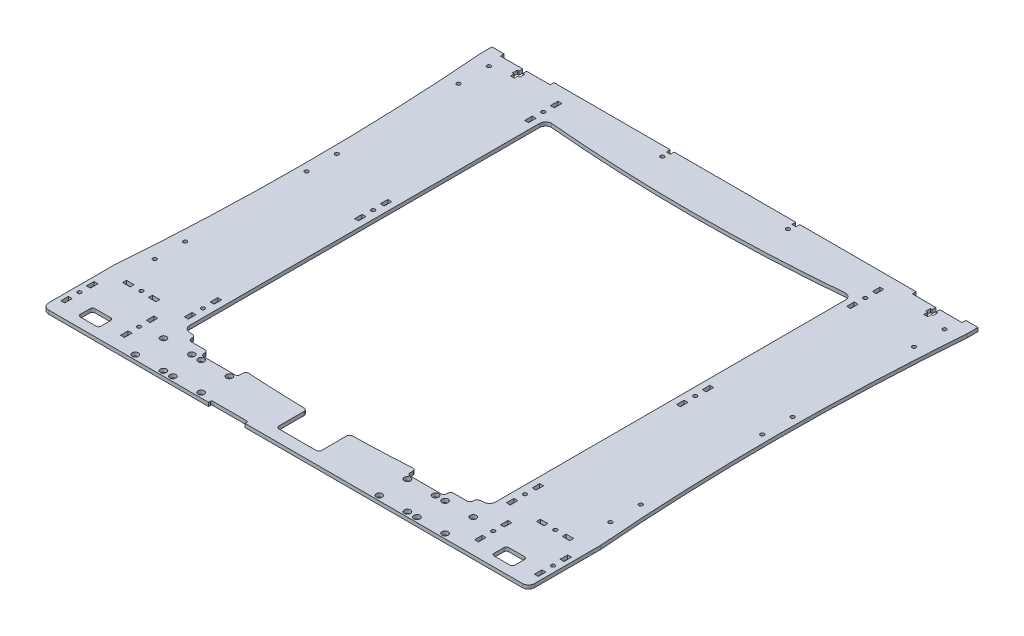
from build123d import *

# Parameters (mm, degrees)
CROQUIS1_W              = 3.2
CROQUIS1_H              = 6.2
CROQUIS1_R              = 1.55
CROQUIS1_R_2            = 2.55
CROQUIS1_W_2            = 6.2
CROQUIS1_H_2            = 3.2
SALIENTE_EXTRUIR1_DEPTH = 3
CORTAR_EXTRUIR1_DEPTH   = 3
REDONDEO1_R             = 5
CORTAR_EXTRUIR3_DEPTH   = 3
CROQUIS5_W              = 30
CROQUIS5_H              = 11
CROQUIS5_W_2            = 35
CROQUIS5_H_2            = 25.246672812
CORTAR_EXTRUIR4_DEPTH   = 3
REDONDEO2_R             = 2
CORTAR_EXTRUIR5_DEPTH   = 3
CROQUIS7_W              = 16
CROQUIS7_H              = 5.5
CORTAR_EXTRUIR6_DEPTH   = 3
REDONDEO3_R             = 2.5


with BuildPart() as part:
    # Croquis1 → Saliente-Extruir1 (new body)
    with BuildSketch(Plane(origin=(0, 0, 0), x_dir=(1, 0, 0), z_dir=(0, 1, 0))):
        Polygon((0, 370), (0, 0), (400, 0), (400, 370), (390, 370), (390, 366.9), (371.6, 366.9), (371.6, 363.9), (373, 363.9), (373, 359.9), (371.6, 359.9), (371.6, 356.9), (368.4, 356.9), (368.4, 359.9), (367, 359.9), (367, 363.9), (368.4, 363.9), (368.4, 366.9), (349, 366.9), (349, 370), (253.3, 370), (253.3, 366.9), (250, 366.9), (250, 370), (150, 370), (150, 366.9), (146.7, 366.9), (146.7, 370), (51, 370), (51, 366.9), (31.6, 366.9), (31.6, 363.9), (33, 363.9), (33, 359.9), (31.6, 359.9), (31.6, 356.9), (28.4, 356.9), (28.4, 359.9), (27, 359.9), (27, 363.9), (28.4, 363.9), (28.4, 366.9), (10, 366.9), (10, 370), align=None)
        with Locations((5.1, 14.7)):
            Rectangle(CROQUIS1_W, CROQUIS1_H, mode=Mode.SUBTRACT)
        with Locations((5.1, 25.3)):
            Circle(CROQUIS1_R, mode=Mode.SUBTRACT)
        with Locations((5.1, 35.9)):
            Rectangle(CROQUIS1_W, CROQUIS1_H, mode=Mode.SUBTRACT)
        with Locations((72.5, 3.9)):
            Circle(CROQUIS1_R_2, mode=Mode.SUBTRACT)
        with Locations((54.3, 14.7)):
            Rectangle(CROQUIS1_W, CROQUIS1_H, mode=Mode.SUBTRACT)
        with Locations((95.7, 3.9)):
            Circle(CROQUIS1_R_2, mode=Mode.SUBTRACT)
        with Locations((54.3, 25.3)):
            Circle(CROQUIS1_R, mode=Mode.SUBTRACT)
        with Locations((72.5, 27.1)):
            Circle(CROQUIS1_R_2, mode=Mode.SUBTRACT)
        with Locations((54.3, 35.9)):
            Rectangle(CROQUIS1_W, CROQUIS1_H, mode=Mode.SUBTRACT)
        with Locations((95.7, 27.1)):
            Circle(CROQUIS1_R_2, mode=Mode.SUBTRACT)
        with Locations((19.1, 51.6)):
            Rectangle(CROQUIS1_W_2, CROQUIS1_H_2, mode=Mode.SUBTRACT)
        with Locations((29.7, 51.8)):
            Circle(CROQUIS1_R, mode=Mode.SUBTRACT)
        with Locations((40.3, 51.6)):
            Rectangle(CROQUIS1_W_2, CROQUIS1_H_2, mode=Mode.SUBTRACT)
        with Locations((12.5, 79.9)):
            Circle(CROQUIS1_R, mode=Mode.SUBTRACT)
        with Locations((67.5, 54.1)):
            Rectangle(CROQUIS1_W, CROQUIS1_H, mode=Mode.SUBTRACT)
        with Locations((67.5, 64.7)):
            Circle(CROQUIS1_R, mode=Mode.SUBTRACT)
        with Locations((67.5, 75.3)):
            Rectangle(CROQUIS1_W, CROQUIS1_H, mode=Mode.SUBTRACT)
        with Locations((103.5, 3.9)):
            Circle(CROQUIS1_R_2, mode=Mode.SUBTRACT)
        with Locations((126.7, 3.9)):
            Circle(CROQUIS1_R_2, mode=Mode.SUBTRACT)
        with Locations((103.5, 27.1)):
            Circle(CROQUIS1_R_2, mode=Mode.SUBTRACT)
        with Locations((126.7, 27.1)):
            Circle(CROQUIS1_R_2, mode=Mode.SUBTRACT)
        with Locations((12.5, 104.9)):
            Circle(CROQUIS1_R, mode=Mode.SUBTRACT)
        with Locations((273.3, 3.9)):
            Circle(CROQUIS1_R_2, mode=Mode.SUBTRACT)
        with Locations((296.5, 3.9)):
            Circle(CROQUIS1_R_2, mode=Mode.SUBTRACT)
        with Locations((273.3, 27.1)):
            Circle(CROQUIS1_R_2, mode=Mode.SUBTRACT)
        with Locations((296.5, 27.1)):
            Circle(CROQUIS1_R_2, mode=Mode.SUBTRACT)
        with Locations((304.3, 3.9)):
            Circle(CROQUIS1_R_2, mode=Mode.SUBTRACT)
        with Locations((327.5, 3.9)):
            Circle(CROQUIS1_R_2, mode=Mode.SUBTRACT)
        with Locations((345.7, 14.7)):
            Rectangle(CROQUIS1_W, CROQUIS1_H, mode=Mode.SUBTRACT)
        with Locations((304.3, 27.1)):
            Circle(CROQUIS1_R_2, mode=Mode.SUBTRACT)
        with Locations((327.5, 27.1)):
            Circle(CROQUIS1_R_2, mode=Mode.SUBTRACT)
        with Locations((345.7, 25.3)):
            Circle(CROQUIS1_R, mode=Mode.SUBTRACT)
        with Locations((345.7, 35.9)):
            Rectangle(CROQUIS1_W, CROQUIS1_H, mode=Mode.SUBTRACT)
        with Locations((394.9, 14.7)):
            Rectangle(CROQUIS1_W, CROQUIS1_H, mode=Mode.SUBTRACT)
        with Locations((394.9, 25.3)):
            Circle(CROQUIS1_R, mode=Mode.SUBTRACT)
        with Locations((394.9, 35.9)):
            Rectangle(CROQUIS1_W, CROQUIS1_H, mode=Mode.SUBTRACT)
        with Locations((332.5, 54.1)):
            Rectangle(CROQUIS1_W, CROQUIS1_H, mode=Mode.SUBTRACT)
        with Locations((332.5, 64.7)):
            Circle(CROQUIS1_R, mode=Mode.SUBTRACT)
        with Locations((332.5, 75.3)):
            Rectangle(CROQUIS1_W, CROQUIS1_H, mode=Mode.SUBTRACT)
        with Locations((359.7, 51.6)):
            Rectangle(CROQUIS1_W_2, CROQUIS1_H_2, mode=Mode.SUBTRACT)
        with Locations((370.3, 51.8)):
            Circle(CROQUIS1_R, mode=Mode.SUBTRACT)
        with Locations((380.9, 51.6)):
            Rectangle(CROQUIS1_W_2, CROQUIS1_H_2, mode=Mode.SUBTRACT)
        with Locations((387.5, 79.9)):
            Circle(CROQUIS1_R, mode=Mode.SUBTRACT)
        with Locations((387.5, 104.9)):
            Circle(CROQUIS1_R, mode=Mode.SUBTRACT)
        with Locations((12.5, 204.9)):
            Circle(CROQUIS1_R, mode=Mode.SUBTRACT)
        with Locations((12.5, 229.9)):
            Circle(CROQUIS1_R, mode=Mode.SUBTRACT)
        with Locations((67.5, 194.1)):
            Rectangle(CROQUIS1_W, CROQUIS1_H, mode=Mode.SUBTRACT)
        with Locations((67.5, 204.7)):
            Circle(CROQUIS1_R, mode=Mode.SUBTRACT)
        with Locations((67.5, 215.3)):
            Rectangle(CROQUIS1_W, CROQUIS1_H, mode=Mode.SUBTRACT)
        with Locations((12.5, 329.9)):
            Circle(CROQUIS1_R, mode=Mode.SUBTRACT)
        with Locations((12.5, 354.9)):
            Circle(CROQUIS1_R, mode=Mode.SUBTRACT)
        with Locations((67.5, 334.1)):
            Rectangle(CROQUIS1_W, CROQUIS1_H, mode=Mode.SUBTRACT)
        with Locations((67.5, 344.7)):
            Circle(CROQUIS1_R, mode=Mode.SUBTRACT)
        with Locations((67.5, 355.3)):
            Rectangle(CROQUIS1_W, CROQUIS1_H, mode=Mode.SUBTRACT)
        with Locations((148.35, 361.9)):
            Circle(CROQUIS1_R, mode=Mode.SUBTRACT)
        with Locations((332.5, 194.1)):
            Rectangle(CROQUIS1_W, CROQUIS1_H, mode=Mode.SUBTRACT)
        with Locations((332.5, 204.7)):
            Circle(CROQUIS1_R, mode=Mode.SUBTRACT)
        with Locations((332.5, 215.3)):
            Rectangle(CROQUIS1_W, CROQUIS1_H, mode=Mode.SUBTRACT)
        with Locations((387.5, 204.9)):
            Circle(CROQUIS1_R, mode=Mode.SUBTRACT)
        with Locations((387.5, 229.9)):
            Circle(CROQUIS1_R, mode=Mode.SUBTRACT)
        with Locations((251.65, 361.9)):
            Circle(CROQUIS1_R, mode=Mode.SUBTRACT)
        with Locations((332.5, 334.1)):
            Rectangle(CROQUIS1_W, CROQUIS1_H, mode=Mode.SUBTRACT)
        with Locations((332.5, 344.7)):
            Circle(CROQUIS1_R, mode=Mode.SUBTRACT)
        with Locations((332.5, 355.3)):
            Rectangle(CROQUIS1_W, CROQUIS1_H, mode=Mode.SUBTRACT)
        with Locations((387.5, 329.9)):
            Circle(CROQUIS1_R, mode=Mode.SUBTRACT)
        with Locations((387.5, 354.9)):
            Circle(CROQUIS1_R, mode=Mode.SUBTRACT)
    extrude(amount=SALIENTE_EXTRUIR1_DEPTH)

    # Croquis2 → Cortar-Extruir1 (cut)
    with BuildSketch(Plane(origin=(0, 3, 0), x_dir=(1, 0, 0), z_dir=(0, 1, 0))):
        with BuildLine():
            Line((74.1, 335), (74.1, 47.1))
            ThreePointArc((74.1, 47.1), (75.564466094, 43.564466094), (79.1, 42.1))
            ThreePointArc((79.1, 42.1), (200, 35.100499668), (320.9, 42.1))
            ThreePointArc((320.9, 42.1), (324.435533906, 43.564466094), (325.9, 47.1))
            Line((325.9, 47.1), (325.9, 335))
            ThreePointArc((325.9, 335), (324.435533906, 338.535533906), (320.9, 340))
            ThreePointArc((320.9, 340), (200, 334.578561616), (79.1, 340))
            ThreePointArc((79.1, 340), (75.564466094, 338.535533906), (74.1, 335))
        make_face()
    extrude(amount=-CORTAR_EXTRUIR1_DEPTH, mode=Mode.SUBTRACT)

    # Redondeo1
    redondeo1_edges = [part.edges().sort_by_distance(p)[0] for p in [
        (400, 1.5, 0),
        (0, 1.5, 0),
    ]]
    fillet(redondeo1_edges, radius=REDONDEO1_R)

    # Croquis4 → Cortar-Extruir3 (cut)
    with BuildSketch(Plane(origin=(0, 3, 0), x_dir=(1, 0, 0), z_dir=(0, 1, 0))):
        with BuildLine():
            ThreePointArc((0, 361), (6, 210.1), (0, 59.2))
            Line((0, 59.2), (0, 361))
        make_face()
        with BuildLine():
            Line((400, 361), (400, 59.2))
            ThreePointArc((400, 59.2), (394, 210.1), (400, 361))
        make_face()
    extrude(amount=-CORTAR_EXTRUIR3_DEPTH, mode=Mode.SUBTRACT)

    # Croquis5 → Cortar-Extruir4 (cut)
    with BuildSketch(Plane(origin=(0, 3, 0), x_dir=(1, 0, 0), z_dir=(0, 1, 0))):
        with Locations((115.100000017, 36)):
            Rectangle(CROQUIS5_W, CROQUIS5_H)
        with Locations((284.899999983, 36)):
            Rectangle(CROQUIS5_W, CROQUIS5_H)
        with Locations((200, 22.623336406)):
            Rectangle(CROQUIS5_W_2, CROQUIS5_H_2)
        with BuildLine():
            Line((23.2, 20), (36.2, 20))
            ThreePointArc((36.2, 20), (37.614213562, 19.414213562), (38.2, 18))
            Line((38.2, 18), (38.2, 10))
            ThreePointArc((38.2, 10), (37.614213562, 8.585786438), (36.2, 8))
            Line((36.2, 8), (23.2, 8))
            ThreePointArc((23.2, 8), (21.785786438, 8.585786438), (21.2, 10))
            Line((21.2, 10), (21.2, 18))
            ThreePointArc((21.2, 18), (21.785786438, 19.414213562), (23.2, 20))
        make_face()
        with BuildLine():
            Line((378.8, 18), (378.8, 10))
            ThreePointArc((378.8, 10), (378.214213562, 8.585786438), (376.8, 8))
            Line((376.8, 8), (363.8, 8))
            ThreePointArc((363.8, 8), (362.385786438, 8.585786438), (361.8, 10))
            Line((361.8, 10), (361.8, 18))
            ThreePointArc((361.8, 18), (362.385786438, 19.414213562), (363.8, 20))
            Line((363.8, 20), (376.8, 20))
            ThreePointArc((376.8, 20), (378.214213562, 19.414213562), (378.8, 18))
        make_face()
    extrude(amount=-CORTAR_EXTRUIR4_DEPTH, mode=Mode.SUBTRACT)

    # Redondeo2
    redondeo2_edges = [part.edges().sort_by_distance(p)[0] for p in [
        (182.5, 1.5, -10),
        (217.5, 1.5, -10),
        (269.899999983, 1.5, -30.5),
        (299.899999983, 1.5, -30.5),
        (100.100000017, 1.5, -30.5),
        (130.100000017, 1.5, -30.5),
    ]]
    fillet(redondeo2_edges, radius=REDONDEO2_R)

    # Croquis6 → Cortar-Extruir5 (cut)
    with BuildSketch(Plane(origin=(0, 3, 0), x_dir=(1, 0, 0), z_dir=(0, 1, 0))):
        with BuildLine():
            Line((136.7, 0), (166.7, 0))
            Line((166.7, 0), (166.7, 1.5))
            ThreePointArc((166.7, 1.5), (166.407106781, 2.207106781), (165.7, 2.5))
            Line((165.7, 2.5), (137.7, 2.5))
            ThreePointArc((137.7, 2.5), (136.992893219, 2.207106781), (136.7, 1.5))
            Line((136.7, 1.5), (136.7, 0))
        make_face()
    extrude(amount=-CORTAR_EXTRUIR5_DEPTH, mode=Mode.SUBTRACT)

    # Croquis7 → Cortar-Extruir6 (cut)
    with BuildSketch(Plane(origin=(0, 3, 0), x_dir=(1, 0, 0), z_dir=(0, 1, 0))):
        with Locations((92.100000017, 38.781270697)):
            Rectangle(CROQUIS7_W, CROQUIS7_H)
        with Locations((307.899999983, 38.781270697)):
            Rectangle(CROQUIS7_W, CROQUIS7_H)
    extrude(amount=-CORTAR_EXTRUIR6_DEPTH, mode=Mode.SUBTRACT)

    # Redondeo3
    redondeo3_edges = [part.edges().sort_by_distance(p)[0] for p in [
        (130.100000017, 1.5, -37.435030967),
        (269.899999983, 1.5, -37.435030967),
        (182.5, 1.5, -35.246672812),
        (217.5, 1.5, -35.246672812),
        (100.100000017, 1.5, -36.031270697),
        (84.100000017, 1.5, -36.031270697),
        (84.100000017, 1.5, -41.531270697),
        (299.899999983, 1.5, -36.031270697),
        (315.899999983, 1.5, -41.531270697),
        (315.899999983, 1.5, -36.031270697),
    ]]
    fillet(redondeo3_edges, radius=REDONDEO3_R)


solid = part.part
